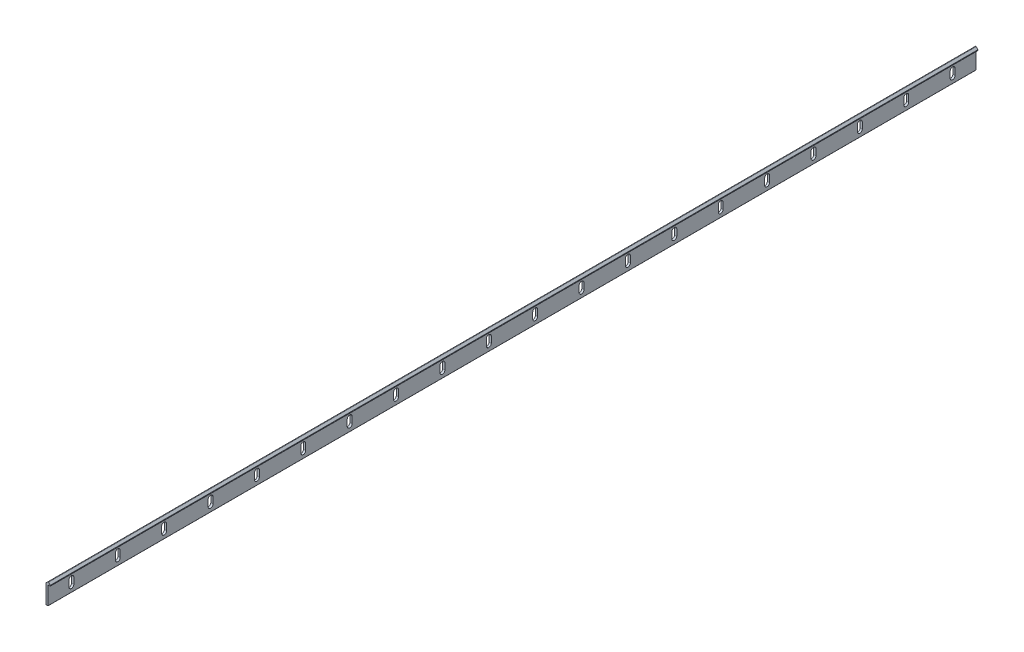
from build123d import *

# Parameters (mm, degrees)
BOSS_EXTRUDE1_DEPTH = 1000
FILLET1_R           = 0.50329666
FILLET2_R           = 0.50398302
FILLET3_R           = 0.30157619
FILLET4_R           = 0.30157551
CUT_EXTRUDE1_DEPTH  = 2.375
LPATTERN1_COUNT     = 20
LPATTERN1_PITCH     = 50


with BuildPart() as part:
    # Sketch1 → Boss-Extrude1 (new body)
    with BuildSketch(Plane.XY):
        with BuildLine():
            Line((0, 20.330194912), (2.019589054, 22.349783966))
            ThreePointArc((2.019589054, 22.349783966), (2.375, 22.497), (2.730410946, 22.349783966))
            Line((2.730410946, 22.349783966), (4.75, 20.330194912))
            Line((4.75, 20.330194912), (4.75, 19.5291))
            Line((4.75, 19.5291), (2.375, 19.5291))
            Line((2.375, 19.5291), (2.375, 0))
            Line((2.375, 0), (0, 0))
            Line((0, 0), (0, 20.330194912))
        make_face()
    extrude(amount=BOSS_EXTRUDE1_DEPTH)

    # Fillet1
    fillet1_edges = [part.edges().sort_by_distance(p)[0] for p in [
        (0, 20.330194912, 500),
    ]]
    fillet(fillet1_edges, radius=FILLET1_R)

    # Fillet2
    fillet2_edges = [part.edges().sort_by_distance(p)[0] for p in [
        (4.75, 20.330194912, 500),
    ]]
    fillet(fillet2_edges, radius=FILLET2_R)

    # Fillet3
    fillet3_edges = [part.edges().sort_by_distance(p)[0] for p in [
        (4.75, 19.5291, 500),
    ]]
    fillet(fillet3_edges, radius=FILLET3_R)

    # Fillet4
    fillet4_edges = [part.edges().sort_by_distance(p)[0] for p in [
        (2.375, 0, 500),
        (0, 0, 500),
    ]]
    fillet(fillet4_edges, radius=FILLET4_R)

    # Sketch2 → Cut-Extrude1 (cut)
    with BuildSketch(Plane.ZY):
        with BuildLine():
            Line((27.65, 13.1043), (27.65, 6.4043))
            ThreePointArc((27.65, 6.4043), (25, 3.7543), (22.35, 6.4043))
            Line((22.35, 6.4043), (22.35, 13.1043))
            ThreePointArc((22.35, 13.1043), (25, 15.7543), (27.65, 13.1043))
        make_face()
    cut_extrude1 = extrude(amount=-CUT_EXTRUDE1_DEPTH, mode=Mode.SUBTRACT)

    # LPattern1: Cut-Extrude1 ×20
    with Locations(*[(0, 0, i * LPATTERN1_PITCH) for i in range(1, LPATTERN1_COUNT)]):
        add(cut_extrude1, mode=Mode.SUBTRACT)


solid = part.part
